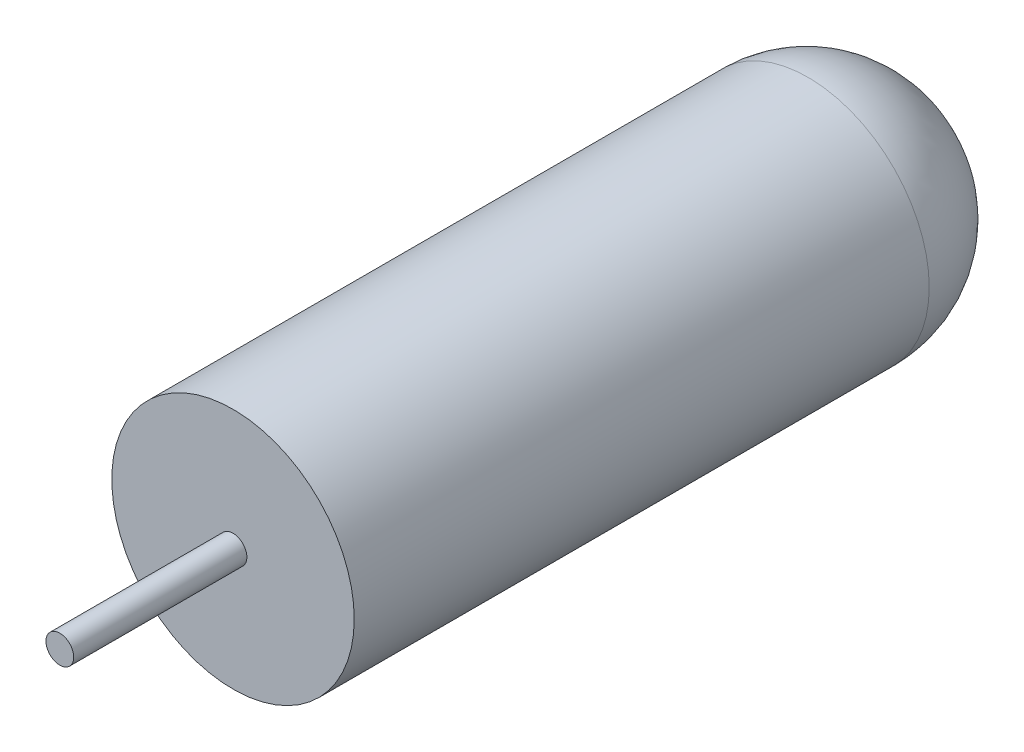
from build123d import *

# Parameters (mm, degrees)
ESQUISSE1_R        = 17.5
BOSS_EXTRU_1_DEPTH = 100
CONG_1_R           = 17
ESQUISSE2_R        = 2
BOSS_EXTRU_2_DEPTH = 25


with BuildPart() as part:
    # Esquisse1 → Boss.-Extru.1 (new body)
    with BuildSketch(Plane.XY):
        Circle(ESQUISSE1_R)
    extrude(amount=BOSS_EXTRU_1_DEPTH)

    # Congé1
    cong_1_edges = [part.edges().sort_by_distance(p)[0] for p in [
        (-17.5, 0, 0),
    ]]
    fillet(cong_1_edges, radius=CONG_1_R)

    # Esquisse2 → Boss.-Extru.2 (add)
    with BuildSketch(Plane.XY.offset(100)):
        Circle(ESQUISSE2_R)
    extrude(amount=BOSS_EXTRU_2_DEPTH)


solid = part.part
